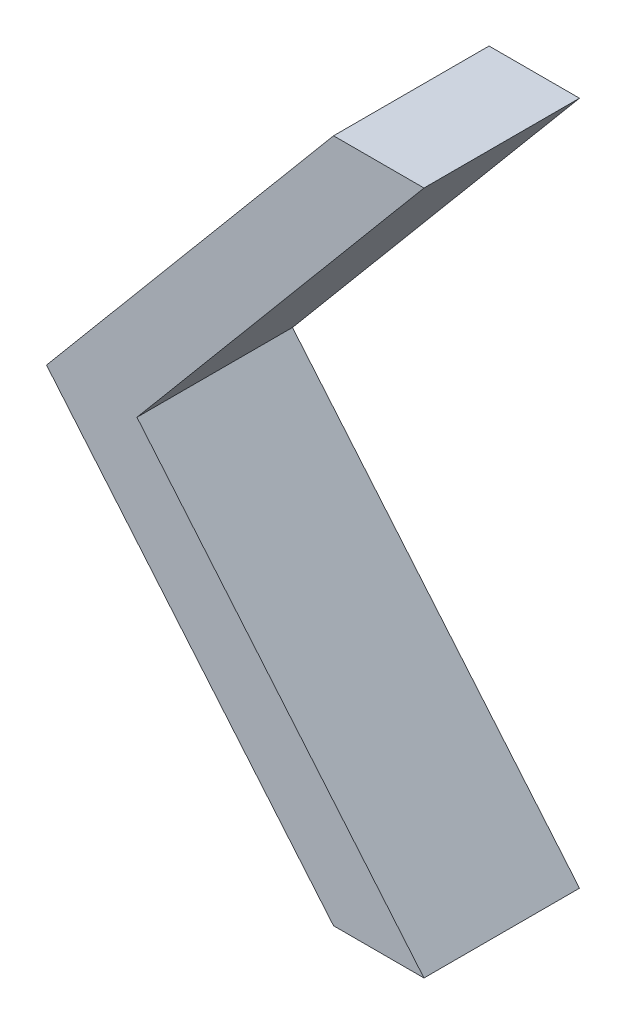
from build123d import *

# Parameters (mm, degrees)
BOSS_EXTRUDE1_DEPTH = 12.5


with BuildPart() as part:
    # Sketch1 → Boss-Extrude1 (new body)
    with BuildSketch(Plane.XY):
        Polygon((0, 0), (-23.075239857, -27.5), (0, -55), (7.27, -55), (-15.805239857, -27.5), (7.27, 0), align=None)
    extrude(amount=BOSS_EXTRUDE1_DEPTH)


solid = part.part
